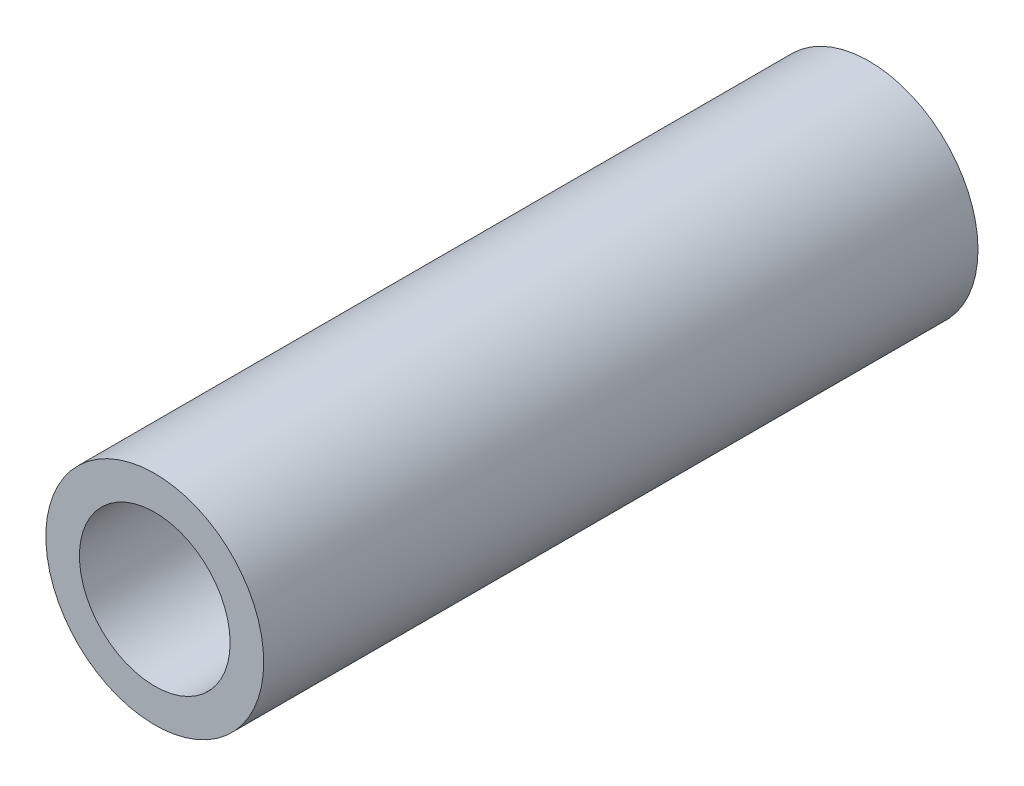
from build123d import *

# Parameters (mm, degrees)
SKETCH1_R           = 7.747
SKETCH1_R_2         = 5.3594
BOSS_EXTRUDE1_DEPTH = 50.8


with BuildPart() as part:
    # Sketch1 → Boss-Extrude1 (new body)
    with BuildSketch(Plane.XY):
        Circle(SKETCH1_R)
        Circle(SKETCH1_R_2, mode=Mode.SUBTRACT)
    extrude(amount=BOSS_EXTRUDE1_DEPTH)


solid = part.part
